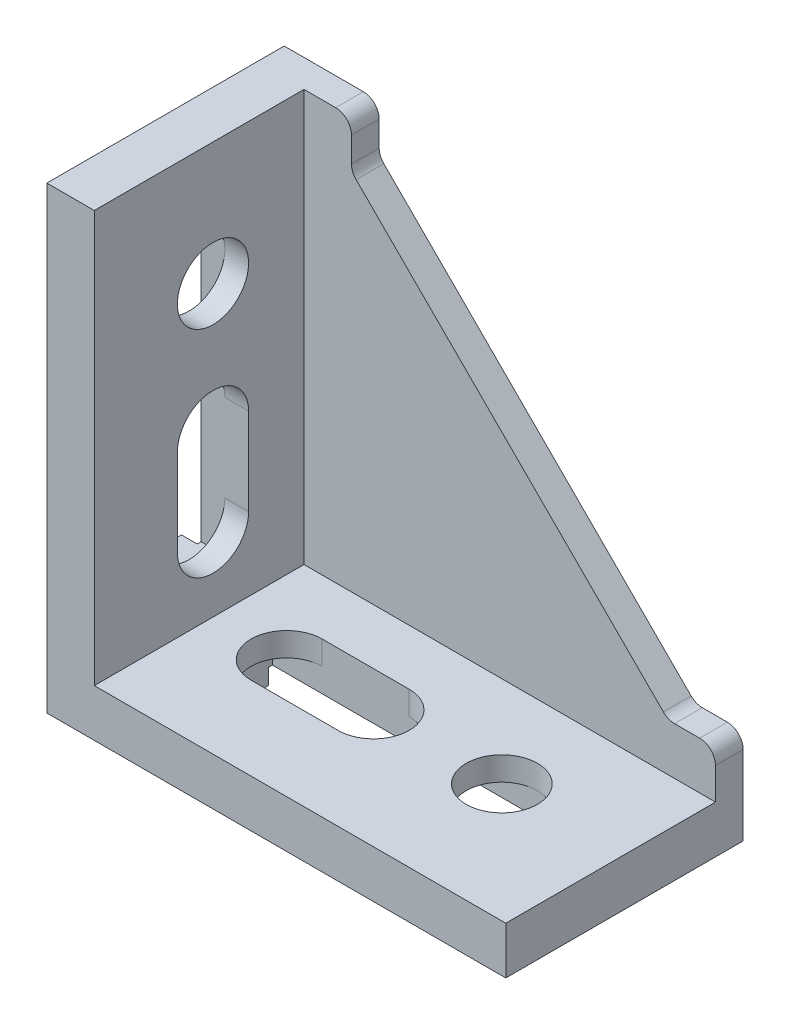
from build123d import *

# Parameters (mm, degrees)
EXTRUDE_1_DEPTH      = 15
EXTRUDE_1_DEPTH_BACK = 15
SKETCH_3_W           = 52
SKETCH_3_H           = 52
CUT_EXTRUDE_1_DEPTH  = 26.5
FILLET_1_R           = 2
SKETCH_4_R           = 4.5
CUT_EXTRUDE_2_DEPTH  = 7
SKETCH_5_R           = 4.5
CUT_EXTRUDE_3_DEPTH  = 7
SKETCH_6_W           = 5
SKETCH_6_H           = 49.5
SKETCH_6_W_2         = 9
SKETCH_6_H_2         = 42
CUT_EXTRUDE_4_DEPTH  = 3
SKETCH_7_W           = 49.5
SKETCH_7_H           = 5
SKETCH_7_W_2         = 42
SKETCH_7_H_2         = 9
CUT_EXTRUDE_5_DEPTH  = 3
SKETCH_8_W           = 3
SKETCH_8_H           = 8
EXTRUDE_2_DEPTH      = 2
SKETCH_9_W           = 8
SKETCH_9_H           = 3
EXTRUDE_3_DEPTH      = 2


with BuildPart() as part:
    # Sketch 2 → Extrude 1 (new body, two sides)
    with BuildSketch(Plane.XY) as extrude_1_sk:
        Polygon((0, 58), (0, 0), (58, 0), (58, 12), (52, 12), (12, 52), (12, 58), align=None)
    extrude(amount=EXTRUDE_1_DEPTH)
    extrude(extrude_1_sk.sketch, amount=-EXTRUDE_1_DEPTH_BACK)

    # Sketch 3 → Cut-Extrude 1 (cut)
    with BuildSketch(Plane.XY.offset(15)):
        with Locations((32, 32)):
            Rectangle(SKETCH_3_W, SKETCH_3_H)
    extrude(amount=-CUT_EXTRUDE_1_DEPTH, mode=Mode.SUBTRACT)

    # Fillet 1
    fillet_1_edges = [part.edges().sort_by_distance(p)[0] for p in [
        (12, 58, -13.25),
        (12, 52, -13.25),
        (52, 12, -13.25),
        (58, 12, -13.25),
    ]]
    fillet(fillet_1_edges, radius=FILLET_1_R)

    # Sketch 4 → Cut-Extrude 2 (cut, through all)
    with BuildSketch(Plane(origin=(6, 0, 0), x_dir=(0, 0, -1), z_dir=(1, 0, 0))):
        with Locations(Location((0, 42.5, 0), (0, 0, 90))):  # turned: the seam where the file's is
            Circle(SKETCH_4_R)
        with BuildLine():
            Line((4.5, 26.3), (4.5, 15.3))
            ThreePointArc((4.5, 15.3), (0, 10.8), (-4.5, 15.3))
            Line((-4.5, 15.3), (-4.5, 26.3))
            ThreePointArc((-4.5, 26.3), (0, 30.8), (4.5, 26.3))
        make_face()
    extrude(amount=-CUT_EXTRUDE_2_DEPTH, mode=Mode.SUBTRACT)

    # Sketch 5 → Cut-Extrude 3 (cut, through all)
    with BuildSketch(Plane(origin=(0, 6, 0), x_dir=(1, 0, 0), z_dir=(0, 1, 0))):
        with Locations(Location((42.5, 0, 0), (0, 0, 270))):  # turned: the seam where the file's is
            Circle(SKETCH_5_R)
        with BuildLine():
            Line((15.3, 4.5), (26.3, 4.5))
            ThreePointArc((26.3, 4.5), (30.8, 0), (26.3, -4.5))
            Line((26.3, -4.5), (15.3, -4.5))
            ThreePointArc((15.3, -4.5), (10.8, 0), (15.3, 4.5))
        make_face()
    extrude(amount=-CUT_EXTRUDE_3_DEPTH, mode=Mode.SUBTRACT)

    # Sketch 6 → Cut-Extrude 4 (cut)
    with BuildSketch(Plane.ZY):
        with Locations((-9.25, 29.75)):
            Rectangle(SKETCH_6_W, SKETCH_6_H)
        with Locations((9.25, 29.75)):
            Rectangle(SKETCH_6_W, SKETCH_6_H)
        with Locations((0, 30)):
            Rectangle(SKETCH_6_W_2, SKETCH_6_H_2)
    extrude(amount=-CUT_EXTRUDE_4_DEPTH, mode=Mode.SUBTRACT)

    # Sketch 7 → Cut-Extrude 5 (cut)
    with BuildSketch(Plane.XZ):
        with Locations((29.75, 9.3)):
            Rectangle(SKETCH_7_W, SKETCH_7_H)
        with Locations((29.75, -9.3)):
            Rectangle(SKETCH_7_W, SKETCH_7_H)
        with Locations((30, 0)):
            Rectangle(SKETCH_7_W_2, SKETCH_7_H_2)
    extrude(amount=-CUT_EXTRUDE_5_DEPTH, mode=Mode.SUBTRACT)

    # Sketch 8 → Extrude 2 (add)
    with BuildSketch(Plane.XZ):
        with Locations((7.5, 0)):
            Rectangle(SKETCH_8_W, SKETCH_8_H)
        with Locations((52.5, 0)):
            Rectangle(SKETCH_8_W, SKETCH_8_H)
    extrude(amount=EXTRUDE_2_DEPTH)

    # Sketch 9 → Extrude 3 (add)
    with BuildSketch(Plane.ZY):
        with Locations((0, 52.5)):
            Rectangle(SKETCH_9_W, SKETCH_9_H)
        with Locations((0, 7.5)):
            Rectangle(SKETCH_9_W, SKETCH_9_H)
    extrude(amount=EXTRUDE_3_DEPTH)


solid = part.part
